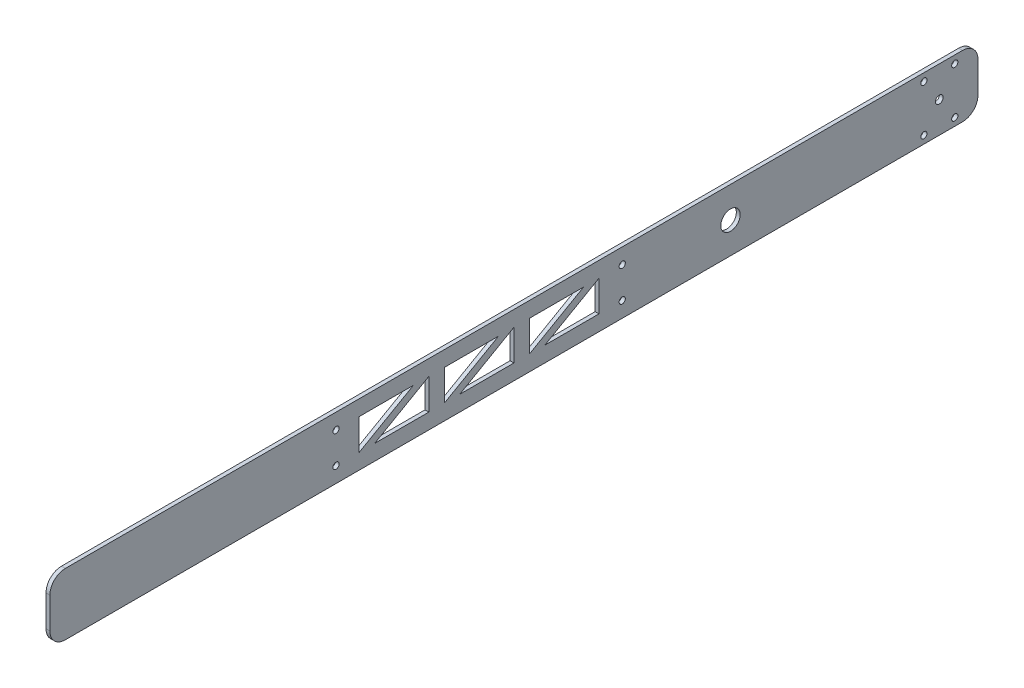
from build123d import *

# Parameters (mm, degrees)
SKETCH1_R           = 7.9629
SKETCH1_R_2         = 3.175
SKETCH1_R_3         = 2.5527
BOSS_EXTRUDE1_DEPTH = 3.175


with BuildPart() as part:
    # Sketch1 → Boss-Extrude1 (new body)
    with BuildSketch(Plane(origin=(0, 0, 0), x_dir=(0, 0, -1), z_dir=(1, 0, 0))):
        with BuildLine():
            Line((177.8, 38.1), (177.8, 12.7))
            ThreePointArc((177.8, 12.7), (174.080256121, 3.719743879), (165.1, 0))
            Line((165.1, 0), (-571.5, 0))
            ThreePointArc((-571.5, 0), (-580.480256121, 3.719743879), (-584.2, 12.7))
            Line((-584.2, 12.7), (-584.2, 38.1))
            ThreePointArc((-584.2, 38.1), (-580.480256121, 47.080256121), (-571.5, 50.8))
            Line((-571.5, 50.8), (165.1, 50.8))
            ThreePointArc((165.1, 50.8), (174.080256121, 47.080256121), (177.8, 38.1))
        make_face()
        with Locations((-25.4, 25.4)):
            Circle(SKETCH1_R, mode=Mode.SUBTRACT)
        with Locations((146.05, 25.4)):
            Circle(SKETCH1_R_2, mode=Mode.SUBTRACT)
        with Locations((-349.25, 38.1)):
            Circle(SKETCH1_R_3, mode=Mode.SUBTRACT)
        with Locations((-349.25, 12.7)):
            Circle(SKETCH1_R_3, mode=Mode.SUBTRACT)
        with Locations((-114.3, 38.1)):
            Circle(SKETCH1_R_3, mode=Mode.SUBTRACT)
        with Locations((-114.3, 12.7)):
            Circle(SKETCH1_R_3, mode=Mode.SUBTRACT)
        with Locations((133.35, 44.45)):
            Circle(SKETCH1_R_3, mode=Mode.SUBTRACT)
        with Locations((158.75, 44.45)):
            Circle(SKETCH1_R_3, mode=Mode.SUBTRACT)
        with Locations((158.75, 6.35)):
            Circle(SKETCH1_R_3, mode=Mode.SUBTRACT)
        with Locations((133.35, 6.35)):
            Circle(SKETCH1_R_3, mode=Mode.SUBTRACT)
        Polygon((-190.5, 38.1), (-146.05, 38.1), (-190.5, 12.7), align=None, mode=Mode.SUBTRACT)
        Polygon((-133.35, 38.1), (-133.35, 12.7), (-177.8, 12.7), align=None, mode=Mode.SUBTRACT)
        Polygon((-203.2, 12.7), (-203.2, 38.1), (-247.65, 12.7), align=None, mode=Mode.SUBTRACT)
        Polygon((-215.9, 38.1), (-260.35, 12.7), (-260.35, 38.1), align=None, mode=Mode.SUBTRACT)
        Polygon((-273.05, 38.1), (-273.05, 12.7), (-317.5, 12.7), align=None, mode=Mode.SUBTRACT)
        Polygon((-330.2, 12.7), (-330.2, 38.1), (-285.75, 38.1), align=None, mode=Mode.SUBTRACT)
    extrude(amount=BOSS_EXTRUDE1_DEPTH)


solid = part.part
